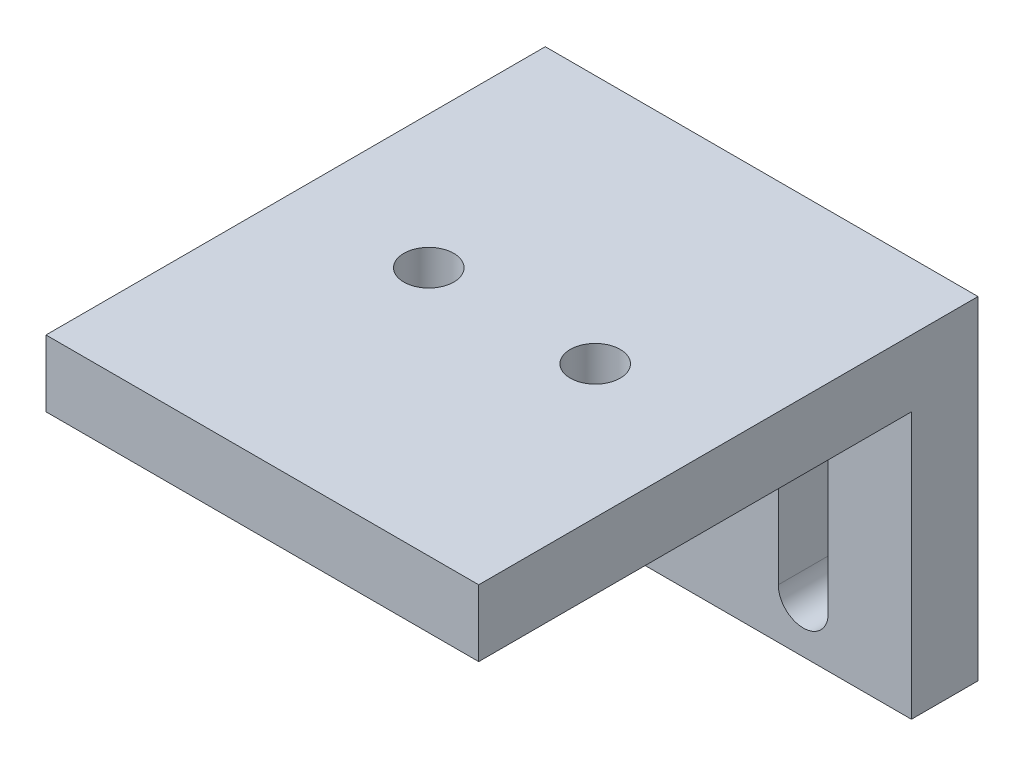
from build123d import *

# Parameters (mm, degrees)
CROQUIS1_W              = 26
CROQUIS1_H              = 4
SALIENTE_EXTRUIR1_DEPTH = 20
CROQUIS2_W              = 26
CROQUIS2_H              = 4
SALIENTE_EXTRUIR2_DEPTH = 26
CROQUIS3_R              = 1.5
CORTAR_EXTRUIR1_DEPTH   = 25
CORTAR_EXTRUIR2_DEPTH   = 25


with BuildPart() as part:
    # Croquis1 → Saliente-Extruir1 (new body)
    with BuildSketch(Plane(origin=(0, 0, 0), x_dir=(1, 0, 0), z_dir=(0, 1, 0))):
        Rectangle(CROQUIS1_W, CROQUIS1_H)
    extrude(amount=SALIENTE_EXTRUIR1_DEPTH)

    # Croquis2 → Saliente-Extruir2 (add)
    with BuildSketch(Plane.XY.offset(2)):
        with Locations((0, 18)):
            Rectangle(CROQUIS2_W, CROQUIS2_H)
    extrude(amount=SALIENTE_EXTRUIR2_DEPTH)

    # Croquis3 → Cortar-Extruir1 (cut)
    with BuildSketch(Plane(origin=(0, 20, 0), x_dir=(1, 0, 0), z_dir=(0, 1, 0))):
        with Locations((-5, -13)):
            Circle(CROQUIS3_R)
        with Locations((5, -13)):
            Circle(CROQUIS3_R)
    extrude(amount=-CORTAR_EXTRUIR1_DEPTH, mode=Mode.SUBTRACT)

    # Croquis4 → Cortar-Extruir2 (cut)
    with BuildSketch(Plane.XY.offset(2)):
        with BuildLine():
            Line((-8, 13), (-8, 3))
            ThreePointArc((-8, 3), (-6.5, 1.5), (-5, 3))
            Line((-5, 3), (-5, 13))
            ThreePointArc((-5, 13), (-6.5, 14.5), (-8, 13))
        make_face()
        with BuildLine():
            Line((5, 13), (5, 3))
            ThreePointArc((5, 3), (6.5, 1.5), (8, 3))
            Line((8, 3), (8, 13))
            ThreePointArc((8, 13), (6.5, 14.5), (5, 13))
        make_face()
    extrude(amount=-CORTAR_EXTRUIR2_DEPTH, mode=Mode.SUBTRACT)


solid = part.part
